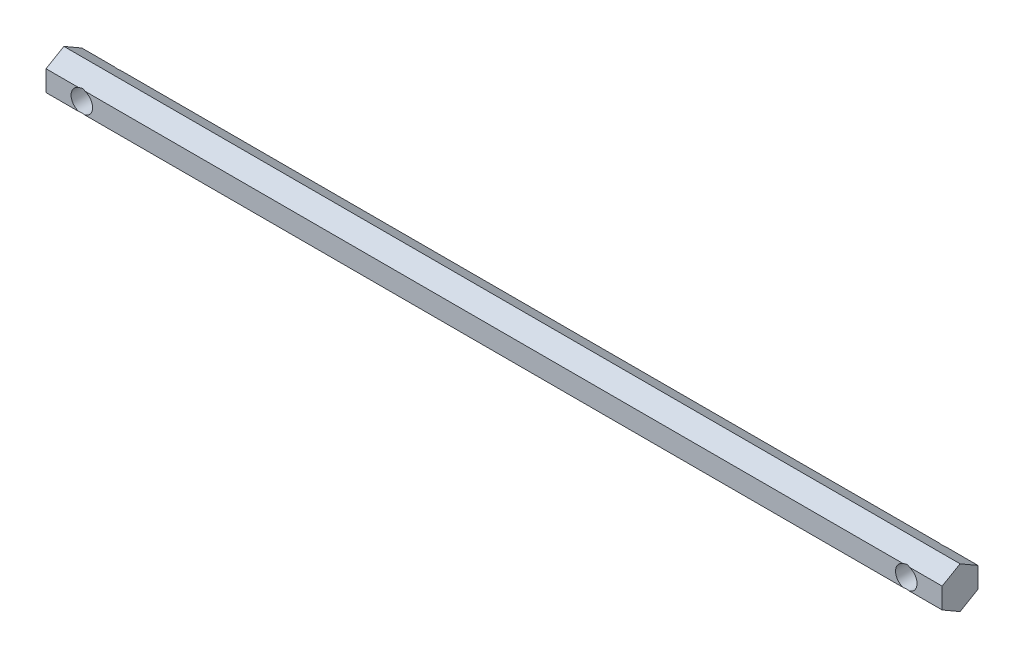
from build123d import *

# Parameters (mm, degrees)
BOSS_EXTRUDE1_DEPTH     = 125
SKETCH2_R               = 3
CUT_EXTRUDE1_DEPTH      = 6
CUT_EXTRUDE1_DEPTH_BACK = 6


with BuildPart() as part:
    # Sketch1 → Boss-Extrude1 (new body, symmetric)
    with BuildSketch(Plane(origin=(0, 0, 0), x_dir=(0, 0, -1), z_dir=(1, 0, 0))):
        Polygon((0, 5.773502692), (-5, 2.886751346), (-5, -2.886751346), (0, -5.773502692), (5, -2.886751346), (5, 2.886751346), align=None)
    extrude(amount=BOSS_EXTRUDE1_DEPTH, both=True)

    # Sketch2 → Cut-Extrude1 (cut, two sides)
    with BuildSketch(Plane.XY) as cut_extrude1_sk:
        with Locations((-115, 0)):
            Circle(SKETCH2_R)
        with Locations((115, 0)):
            Circle(SKETCH2_R)
    extrude(amount=CUT_EXTRUDE1_DEPTH, mode=Mode.SUBTRACT)
    extrude(cut_extrude1_sk.sketch, amount=-CUT_EXTRUDE1_DEPTH_BACK, mode=Mode.SUBTRACT)


solid = part.part
